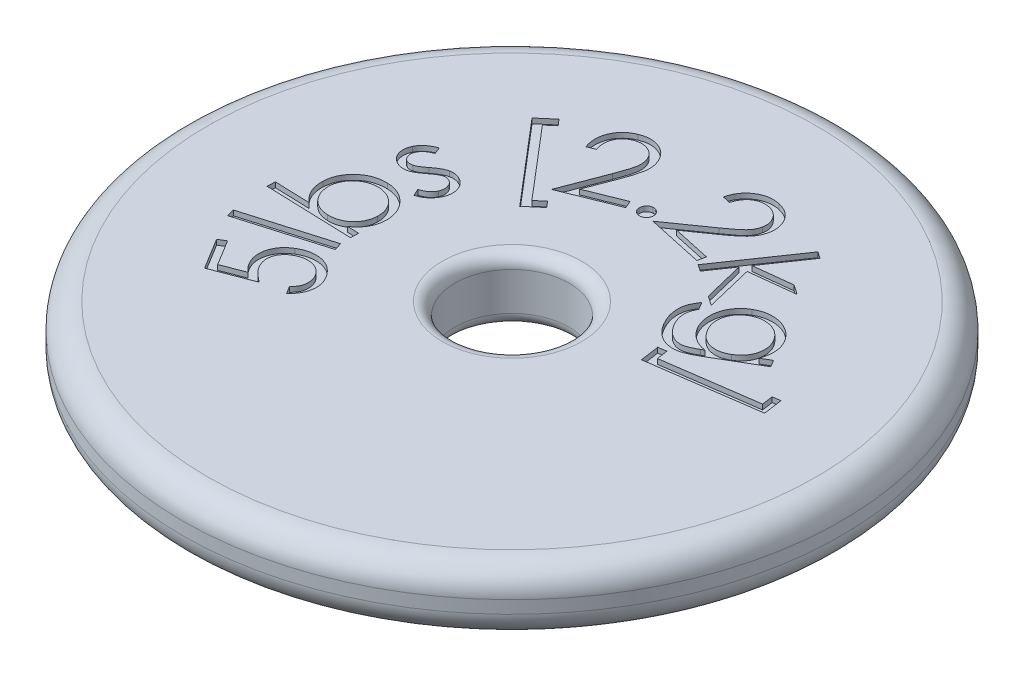
from build123d import *

# Parameters (mm, degrees)
SKETCH1_R           = 82.55
SKETCH1_R_2         = 14.2875
BOSS_EXTRUDE1_DEPTH = 7.9375
FILLET1_R           = 6.35
FILLET2_R           = 3.175
CUT_EXTRUDE1_DEPTH  = 1.27


with BuildPart() as part:
    # Sketch1 → Boss-Extrude1 (new body, symmetric)
    with BuildSketch(Plane(origin=(0, 0, 0), x_dir=(1, 0, 0), z_dir=(0, 1, 0))):
        Circle(SKETCH1_R)
        Circle(SKETCH1_R_2, mode=Mode.SUBTRACT)
    extrude(amount=BOSS_EXTRUDE1_DEPTH, both=True)

    # Fillet1
    fillet1_edges = [part.edges().sort_by_distance(p)[0] for p in [
        (-82.55, -7.9375, 0),
        (-82.55, 7.9375, 0),
    ]]
    fillet(fillet1_edges, radius=FILLET1_R)

    # Fillet2
    fillet2_edges = [part.edges().sort_by_distance(p)[0] for p in [
        (-14.2875, -7.9375, 0),
        (-14.2875, 7.9375, 0),
    ]]
    fillet(fillet2_edges, radius=FILLET2_R)

    # Sketch2 → Cut-Extrude1 (cut)
    with BuildSketch(Plane(origin=(0, 7.9375, 0), x_dir=(1, 0, 0), z_dir=(0, 1, 0))):
        Polygon((28.879652336, 3.539902753), (28.201233532, 8.30155473), (30.215289355, 8.585642603), (30.609620285, 5.82108598), (53.675859601, 9.107177059), (53.281528671, 11.871733683), (55.223502496, 12.147341321), (55.9019213, 7.385689345), align=None)
        with BuildLine():
            Line((45.56731607, 19.958879369), (46.584944275, 18.224671303))
            Line((46.584944275, 18.224671303), (35.899848121, 11.953537488))
            add(Edge.make_bspline(
                [(35.899848121, 11.953537488), (35.671200726, 11.822955682), (35.230003179, 11.570985297), (34.586055553, 11.215088871), (33.975223552, 10.910614423), (33.403679251, 10.64836999), (32.872861952, 10.422297335), (32.376523988, 10.252786494), (31.922142406, 10.108394493), (31.626452631, 10.051385369), (31.485885781, 10.024284016)],
                knots=[0, 0, 0, 0, 0.000789937, 0.001524262, 0.002206907, 0.002836804, 0.003410851, 0.003936523, 0.00441007, 0.004839182, 0.004839182, 0.004839182, 0.004839182], degree=3))
            add(Edge.make_bspline(
                [(31.485885781, 10.024284016), (31.299662275, 9.996159396), (30.932770023, 9.94074907), (30.380946149, 9.904805731), (29.8393038, 9.924686489), (29.303631844, 9.980933386), (28.778538099, 10.095007428), (28.257476375, 10.244968967), (27.749217659, 10.452639422), (27.246880057, 10.696893046), (26.762173723, 10.99035698), (26.292463873, 11.320969465), (25.84756059, 11.698836362), (25.414312004, 12.108097474), (25.002724881, 12.559344404), (24.611370368, 13.050023572), (24.237887164, 13.579862692), (24.0084847, 13.954949483), (23.891835301, 14.145678247)],
                knots=[0, 0, 0, 0, 0.000564875, 0.001112901, 0.001655901, 0.00218923, 0.002726438, 0.003265783, 0.003813793, 0.0043713, 0.00493995, 0.005511722, 0.006092618, 0.006689451, 0.007298687, 0.007923137, 0.00857132, 0.009241903, 0.009241903, 0.009241903, 0.009241903], degree=3))
            add(Edge.make_bspline(
                [(23.891835301, 14.145678247), (23.733427788, 14.430337114), (23.424521713, 14.985442435), (23.043888814, 15.838134554), (22.75534599, 16.683099408), (22.5491563, 17.51451422), (22.432332093, 18.322844179), (22.385169119, 19.097966988), (22.423543849, 19.834414752), (22.537560611, 20.546044595), (22.754359642, 21.254567288), (23.075169937, 21.986552812), (23.495281412, 22.758292423), (23.83659934, 23.267464012), (24.014798709, 23.533298439)],
                knots=[0, 0, 0, 0, 0.000976977, 0.001905175, 0.002796861, 0.003652483, 0.004471001, 0.005243866, 0.005978399, 0.006678955, 0.007400648, 0.008194581, 0.009073063, 0.010032764, 0.010032764, 0.010032764, 0.010032764], degree=3))
            Line((24.014798709, 23.533298439), (25.117229264, 21.659166495))
            add(Edge.make_bspline(
                [(25.117229264, 21.659166495), (24.983319157, 21.403609578), (24.72232343, 20.905519743), (24.449957881, 20.118513977), (24.305568591, 19.324953184), (24.277810737, 18.52292662), (24.380774789, 17.707386517), (24.607026167, 16.874082664), (24.949090862, 16.012690051), (25.25766562, 15.454067411), (25.418277608, 15.163306452)],
                knots=[0, 0, 0, 0, 0.000864703, 0.001685339, 0.002487068, 0.003276141, 0.004083435, 0.004943249, 0.005860536, 0.006856242, 0.006856242, 0.006856242, 0.006856242], degree=3))
            add(Edge.make_bspline(
                [(25.418277608, 15.163306452), (25.503960746, 15.01929734), (25.671677385, 14.737413123), (25.951740571, 14.343407735), (26.233442888, 13.972217777), (26.531041692, 13.633703963), (26.836378123, 13.323147945), (27.151016631, 13.041174498), (27.478186491, 12.789795285), (27.922669049, 12.502955216), (28.482511876, 12.208855008), (29.160864236, 11.9579273), (29.832231358, 11.817035276), (30.393619511, 11.794948432), (30.849172436, 11.849342287), (31.220157804, 11.920588944), (31.618546172, 12.038761971), (32.046208114, 12.191167293), (32.501059407, 12.384301515), (32.98435068, 12.614337057), (33.49700409, 12.880487356), (33.842746158, 13.080022645), (34.021476059, 13.18317157)],
                knots=[0, 0, 0, 0, 0.000502503, 0.000983602, 0.001449205, 0.001899936, 0.002334687, 0.002755122, 0.003166436, 0.003571006, 0.004340993, 0.005058626, 0.005733857, 0.006391417, 0.006732766, 0.007108633, 0.00752332, 0.007977963, 0.008470145, 0.009005005, 0.009583436, 0.010202449, 0.010202449, 0.010202449, 0.010202449], degree=3))
            Line((34.021476059, 13.18317157), (34.712615215, 13.585982734))
            add(Edge.make_bspline(
                [(34.712615215, 13.585982734), (34.416939375, 13.636671292), (33.829721649, 13.737339713), (32.982840037, 14.015923063), (32.173491788, 14.381448472), (31.413683963, 14.845397756), (30.704277698, 15.385485944), (30.0668552, 16.006457432), (29.489692286, 16.690878864), (29.170697398, 17.197306686), (29.009657149, 17.452969914)],
                knots=[0, 0, 0, 0, 0.000898915, 0.001785262, 0.002665707, 0.003557957, 0.004450126, 0.005334727, 0.006222897, 0.007128418, 0.007128418, 0.007128418, 0.007128418], degree=3))
            add(Edge.make_bspline(
                [(29.009657149, 17.452969914), (28.922932741, 17.607426759), (28.749821538, 17.91573916), (28.526333513, 18.392728023), (28.33768262, 18.881948641), (28.183648389, 19.379814774), (28.051726052, 19.88661849), (27.966583935, 20.404957313), (27.905071628, 20.931239586), (27.880688592, 21.463859394), (27.888229911, 21.996426455), (27.932380619, 22.521448715), (28.000882631, 23.036716393), (28.115159723, 23.538273957), (28.252742518, 24.030823072), (28.427630359, 24.511042285), (28.635806899, 24.978634267), (28.877425383, 25.431609238), (29.149886628, 25.867959618), (29.444955837, 26.287306894), (29.767349166, 26.684725719), (30.12351507, 27.051078288), (30.494010487, 27.407595191), (30.89966893, 27.730390587), (31.324095214, 28.040802631), (31.625782644, 28.223629871), (31.77845389, 28.316151003)],
                knots=[0, 0, 0, 0, 0.000531285, 0.001060502, 0.00157863, 0.002102984, 0.002623345, 0.003148246, 0.003677361, 0.004212222, 0.004746544, 0.005274025, 0.005792118, 0.006304454, 0.006815823, 0.00732552, 0.007836115, 0.008350167, 0.008864342, 0.009378446, 0.009887702, 0.010397539, 0.010910453, 0.011428963, 0.011951444, 0.012486741, 0.012486741, 0.012486741, 0.012486741], degree=3))
            add(Edge.make_bspline(
                [(31.77845389, 28.316151003), (31.934020926, 28.404917325), (32.242371154, 28.580861513), (32.7255631, 28.798503611), (33.212667848, 28.991635971), (33.710126724, 29.148341801), (34.217082994, 29.272341256), (34.732910941, 29.360451278), (35.25832248, 29.416257409), (35.78948233, 29.436835386), (36.321972842, 29.424391053), (36.848961582, 29.378069527), (37.368529724, 29.296276579), (37.881148236, 29.184577251), (38.382138245, 29.028021435), (38.877922082, 28.846791987), (39.363613277, 28.626351926), (39.838175741, 28.370652763), (40.296675545, 28.090575532), (40.730595112, 27.781748153), (41.143882893, 27.45809397), (41.525090681, 27.103606006), (41.882026051, 26.729935153), (42.215117776, 26.335631661), (42.515935074, 25.913437363), (42.69833683, 25.619040045), (42.790039093, 25.471032147)],
                knots=[0, 0, 0, 0, 0.000537041, 0.001064471, 0.001588087, 0.002108396, 0.002627737, 0.003152639, 0.003677078, 0.004211753, 0.00474616, 0.005273999, 0.005797529, 0.006323201, 0.006846302, 0.007370861, 0.007906007, 0.008444752, 0.008987255, 0.009516642, 0.010041766, 0.010560882, 0.011076715, 0.011591378, 0.012107942, 0.012630217, 0.012630217, 0.012630217, 0.012630217], degree=3))
            add(Edge.make_bspline(
                [(42.790039093, 25.471032147), (42.929227178, 25.219655952), (43.20359819, 24.72413695), (43.502609163, 23.932736591), (43.718479445, 23.126374292), (43.833201831, 22.291989523), (43.850602641, 21.426574943), (43.75629599, 20.51804658), (43.556869677, 19.563192371), (43.347619717, 18.923906931), (43.239491551, 18.593561527)],
                knots=[0, 0, 0, 0, 0.000861026, 0.001697275, 0.002530326, 0.003360838, 0.004217509, 0.005120813, 0.006095432, 0.007137578, 0.007137578, 0.007137578, 0.007137578], degree=3))
            Line((43.239491551, 18.593561527), (45.56731607, 19.958879369))
        make_face()
        with BuildLine():
            add(Edge.make_bspline(
                [(41.259356668, 24.275319006), (41.110048635, 24.511571638), (40.815001553, 24.978429639), (40.266354959, 25.59784455), (39.648641984, 26.140087471), (38.962295849, 26.597110363), (38.226202494, 26.959336996), (37.457468643, 27.230404975), (36.654860729, 27.374862127), (35.83600033, 27.422183601), (35.015882391, 27.364225685), (34.214976463, 27.196368344), (33.43923938, 26.925745342), (32.955553423, 26.666318686), (32.711279745, 26.535301644)],
                knots=[0, 0, 0, 0, 0.000837313, 0.001654612, 0.00247191, 0.00329746, 0.004120436, 0.004927664, 0.005734334, 0.006558238, 0.00738296, 0.008192922, 0.009006948, 0.009837502, 0.009837502, 0.009837502, 0.009837502], degree=3))
            add(Edge.make_bspline(
                [(32.711279745, 26.535301644), (32.533721205, 26.425610883), (32.184777934, 26.210043369), (31.70843204, 25.833569288), (31.282565057, 25.425840206), (30.907825268, 24.986830605), (30.579813446, 24.518077356), (30.315748927, 24.009413483), (30.092775734, 23.473962242), (29.925028683, 22.911157379), (29.808877926, 22.333640827), (29.759250737, 21.747855135), (29.766040311, 21.16086659), (29.840430461, 20.572899286), (29.972874258, 19.985224144), (30.164760297, 19.397100557), (30.421082253, 18.808987326), (30.631849133, 18.427980141), (30.739625098, 18.233151538)],
                knots=[0, 0, 0, 0, 0.000625701, 0.001229646, 0.001817419, 0.002391841, 0.00295875, 0.003529672, 0.004107636, 0.004696524, 0.005288594, 0.005871714, 0.006456912, 0.007046471, 0.007646189, 0.008261649, 0.008899699, 0.009567393, 0.009567393, 0.009567393, 0.009567393], degree=3))
            add(Edge.make_bspline(
                [(30.739625098, 18.233151538), (30.857851389, 18.041520729), (31.088352938, 17.667905033), (31.483431388, 17.155540958), (31.902580227, 16.696631827), (32.347811745, 16.290558577), (32.824180289, 15.945072653), (33.324584227, 15.648439543), (33.859205025, 15.417929199), (34.411352176, 15.232879381), (34.980976007, 15.11603365), (35.554808727, 15.05601247), (36.131961781, 15.055165436), (36.710682378, 15.119393371), (37.289641629, 15.24897242), (37.870315748, 15.4372977), (38.452301031, 15.687424735), (38.828648125, 15.896319323), (39.020574617, 16.002849721)],
                knots=[0, 0, 0, 0, 0.000675125, 0.001316266, 0.001937483, 0.002537876, 0.003120518, 0.003700113, 0.004279164, 0.004863778, 0.005444225, 0.006019711, 0.006592127, 0.007172279, 0.007762798, 0.008368883, 0.009001358, 0.009659573, 0.009659573, 0.009659573, 0.009659573], degree=3))
            add(Edge.make_bspline(
                [(39.020574617, 16.002849721), (39.261942646, 16.155562903), (39.735665137, 16.455286396), (40.366968829, 16.99206202), (40.902470509, 17.593833047), (41.350039509, 18.246623151), (41.697977524, 18.94799263), (41.947290978, 19.685168748), (42.09263813, 20.454316078), (42.128064065, 21.245907325), (42.065148612, 22.039473511), (41.902860655, 22.817563898), (41.642364124, 23.571951533), (41.387707687, 24.039610978), (41.259356668, 24.275319006)],
                knots=[0, 0, 0, 0, 0.000856126, 0.001680281, 0.00247608, 0.003266393, 0.004047645, 0.004817294, 0.005594011, 0.006387831, 0.007187506, 0.007975849, 0.00876706, 0.009571085, 0.009571085, 0.009571085, 0.009571085], degree=3))
        make_face(mode=Mode.SUBTRACT)
        Polygon((27.57659226, 49.061848625), (29.238718328, 47.917016895), (22.284925593, 37.800096489), (31.765828371, 38.889806692), (34.195415711, 37.219200388), (22.954864162, 35.938684897), (25.795742901, 24.104516895), (23.459438147, 25.711521435), (20.983209514, 35.900523839), (17.018699632, 30.13396401), (15.356573564, 31.278795741), align=None)
        with BuildLine():
            Line((5.786038782, 48.696133268), (3.8059039, 49.124385138))
            add(Edge.make_bspline(
                [(3.8059039, 49.124385138), (3.87220874, 49.371687681), (4.002383575, 49.857211332), (4.268934345, 50.550191258), (4.579769011, 51.199148228), (4.954377202, 51.794187481), (5.367654793, 52.349297231), (5.840102258, 52.853330809), (6.360954961, 53.311033977), (6.929725035, 53.71766144), (7.530560963, 54.066341349), (8.153184558, 54.353861909), (8.791417815, 54.570470438), (9.444865337, 54.720922841), (10.11435772, 54.799584982), (10.798708067, 54.818237069), (11.499341596, 54.762891214), (11.964574552, 54.673533022), (12.201336592, 54.62805768)],
                knots=[0, 0, 0, 0, 0.000767637, 0.001507085, 0.002223903, 0.002922802, 0.003613096, 0.00429711, 0.004991156, 0.005690094, 0.006391164, 0.007072294, 0.007744068, 0.008409564, 0.009080119, 0.009762989, 0.010460549, 0.011183424, 0.011183424, 0.011183424, 0.011183424], degree=3))
            add(Edge.make_bspline(
                [(12.201336592, 54.62805768), (12.432913755, 54.572953678), (12.886414315, 54.465042796), (13.532609266, 54.234478368), (14.13180696, 53.95299056), (14.683992008, 53.621412473), (15.194432177, 53.242828924), (15.65249295, 52.808733022), (16.062676249, 52.323966475), (16.424781869, 51.798185656), (16.729728369, 51.240235534), (16.989035965, 50.672509139), (17.177961668, 50.091231471), (17.31761605, 49.504746904), (17.388919372, 48.905855118), (17.399095987, 48.299919264), (17.361575105, 47.684084709), (17.282755316, 47.277889481), (17.242836325, 47.072168257)],
                knots=[0, 0, 0, 0, 0.000713714, 0.001397675, 0.002053949, 0.002696771, 0.003326853, 0.003956735, 0.004585432, 0.005228771, 0.005868355, 0.006490887, 0.00709829, 0.007698952, 0.008296929, 0.008903399, 0.009515446, 0.010143514, 0.010143514, 0.010143514, 0.010143514], degree=3))
            add(Edge.make_bspline(
                [(17.242836325, 47.072168257), (17.169732929, 46.78566401), (17.024817906, 46.217718173), (16.676350694, 45.410388067), (16.239272673, 44.648840443), (15.7826189, 44.057082187), (15.355098337, 43.592248104), (14.974950753, 43.21828243), (14.538625493, 42.821701024), (14.045842711, 42.400803736), (13.492850331, 41.962027012), (12.885889874, 41.494409129), (12.221616537, 41.003657079), (11.755343711, 40.674361321), (11.514437554, 40.504226217)],
                knots=[0, 0, 0, 0, 0.00088587, 0.001756086, 0.002628078, 0.003514303, 0.003991481, 0.004522174, 0.005113438, 0.005760066, 0.006465966, 0.007230941, 0.008058633, 0.008943396, 0.008943396, 0.008943396, 0.008943396], degree=3))
            Line((11.514437554, 40.504226217), (5.175461859, 36.064823172))
            Line((5.175461859, 36.064823172), (14.711486165, 34.004126056))
            Line((14.711486165, 34.004126056), (14.278994178, 32.011270821))
            Line((14.278994178, 32.011270821), (0.248445299, 35.042954849))
            Line((0.248445299, 35.042954849), (9.987995246, 41.865303941))
            add(Edge.make_bspline(
                [(9.987995246, 41.865303941), (10.224423761, 42.030106993), (10.67934515, 42.347211016), (11.327614042, 42.812466405), (11.913415683, 43.248560951), (12.435862842, 43.656483723), (12.898993135, 44.033008707), (13.300348855, 44.379579369), (13.64431134, 44.691944952), (14.008619789, 45.074790315), (14.393980492, 45.546774963), (14.761559676, 46.152010244), (15.048091893, 46.791389406), (15.165642854, 47.241151276), (15.224540385, 47.466499187)],
                knots=[0, 0, 0, 0, 0.000864589, 0.00166359, 0.00239374, 0.00305532, 0.003651988, 0.004184102, 0.004646177, 0.005045041, 0.005768823, 0.00646911, 0.007163972, 0.007861726, 0.007861726, 0.007861726, 0.007861726], degree=3))
            add(Edge.make_bspline(
                [(15.224540385, 47.466499187), (15.252006503, 47.610223212), (15.306081577, 47.893185924), (15.327022545, 48.321415823), (15.317833592, 48.743295584), (15.257733807, 49.160236677), (15.150324269, 49.569040723), (14.999964901, 49.970420009), (14.809146083, 50.365556805), (14.575133402, 50.748247594), (14.313690459, 51.115708282), (14.013430697, 51.446508392), (13.691451676, 51.74715539), (13.33633633, 52.005135802), (12.957594823, 52.231425599), (12.552519529, 52.421645871), (12.122334483, 52.582598889), (11.820671228, 52.653980563), (11.667081784, 52.690323973)],
                knots=[0, 0, 0, 0, 0.000438458, 0.000863232, 0.001283196, 0.001702947, 0.002123574, 0.002548877, 0.002986945, 0.003437795, 0.003893248, 0.004337631, 0.00477574, 0.005212493, 0.005651709, 0.006097426, 0.006553509, 0.007026582, 0.007026582, 0.007026582, 0.007026582], degree=3))
            add(Edge.make_bspline(
                [(11.667081784, 52.690323973), (11.505021779, 52.72175045), (11.185578287, 52.783696538), (10.705155055, 52.820833649), (10.23693339, 52.811456873), (9.779882624, 52.763856542), (9.337589956, 52.658627836), (8.905231083, 52.514386903), (8.484596447, 52.322597498), (8.078395934, 52.085302301), (7.693198541, 51.805911397), (7.332133581, 51.484887946), (7.004932504, 51.119516107), (6.698278901, 50.71804856), (6.430517839, 50.270094309), (6.182307269, 49.785513163), (5.966182299, 49.257123869), (5.847134874, 48.886394532), (5.786038782, 48.696133268)],
                knots=[0, 0, 0, 0, 0.000494933, 0.000975583, 0.001442073, 0.00189861, 0.002351172, 0.002803038, 0.00326414, 0.003735385, 0.004212035, 0.004689514, 0.005181806, 0.005681295, 0.006202692, 0.006745029, 0.007313537, 0.007912895, 0.007912895, 0.007912895, 0.007912895], degree=3))
        make_face()
        with BuildLine():
            add(Edge.make_bspline(
                [(-2.738163767, 38.064674253), (-2.620649897, 38.067682738), (-2.389022811, 38.073612648), (-2.047519474, 38.005672535), (-1.732453424, 37.85956108), (-1.445882045, 37.656129363), (-1.197941311, 37.406383725), (-1.004897053, 37.115111604), (-0.878297849, 36.786225882), (-0.849221942, 36.552016141), (-0.834351, 36.432229008)],
                knots=[0, 0, 0, 0, 0.000351955, 0.000693726, 0.001033412, 0.001386336, 0.001743136, 0.002083008, 0.00242792, 0.002789003, 0.002789003, 0.002789003, 0.002789003], degree=3))
            add(Edge.make_bspline(
                [(-0.834351, 36.432229008), (-0.828683236, 36.313100523), (-0.817629, 36.080755912), (-0.897643754, 35.740972178), (-1.033377332, 35.421167854), (-1.23802148, 35.133768874), (-1.48404598, 34.881764511), (-1.775639175, 34.692825181), (-2.09750204, 34.558840894), (-2.328433454, 34.53021774), (-2.445595658, 34.515695888)],
                knots=[0, 0, 0, 0, 0.00035617, 0.000694663, 0.001036512, 0.001392909, 0.001746699, 0.00208657, 0.002429076, 0.002781797, 0.002781797, 0.002781797, 0.002781797], degree=3))
            add(Edge.make_bspline(
                [(-2.445595658, 34.515695888), (-2.563257429, 34.512104405), (-2.795465842, 34.505016525), (-3.134546265, 34.581412153), (-3.454271276, 34.720141629), (-3.740091795, 34.926679448), (-3.987303804, 35.179920222), (-4.176997862, 35.471985952), (-4.304196706, 35.797199394), (-4.336967882, 36.026954659), (-4.353648543, 36.143901016)],
                knots=[0, 0, 0, 0, 0.000351955, 0.000694592, 0.001032554, 0.001391389, 0.00174523, 0.002088653, 0.002429607, 0.002783066, 0.002783066, 0.002783066, 0.002783066], degree=3))
            add(Edge.make_bspline(
                [(-4.353648543, 36.143901016), (-4.356862744, 36.264301321), (-4.363161772, 36.500255702), (-4.293387308, 36.845894244), (-4.1550315, 37.16681453), (-3.948827647, 37.452887634), (-3.699768515, 37.701245935), (-3.409251583, 37.893011318), (-3.085200026, 38.020291523), (-2.855143329, 38.049713648), (-2.738163767, 38.064674253)],
                knots=[0, 0, 0, 0, 0.000360435, 0.000706362, 0.001048211, 0.001401136, 0.001757936, 0.002097807, 0.002438761, 0.002791482, 0.002791482, 0.002791482, 0.002791482], degree=3))
        make_face()
        with BuildLine():
            Line((-22.416178273, 43.55267689), (-24.2860701, 42.797935971))
            add(Edge.make_bspline(
                [(-24.2860701, 42.797935971), (-24.369582099, 43.038313387), (-24.533697512, 43.510696277), (-24.701448395, 44.230873761), (-24.807099917, 44.940050288), (-24.834071287, 45.638885327), (-24.803792276, 46.328113892), (-24.694041554, 47.006181578), (-24.526821079, 47.676726481), (-24.282441611, 48.326653525), (-23.985068597, 48.950798426), (-23.632549632, 49.533015252), (-23.230247421, 50.069547792), (-22.776594917, 50.55674721), (-22.270266674, 50.998042896), (-21.714900318, 51.391222922), (-21.108862212, 51.739018473), (-20.676910736, 51.925405428), (-20.457243978, 52.02019158)],
                knots=[0, 0, 0, 0, 0.00076295, 0.001499328, 0.002214703, 0.002910715, 0.003594216, 0.004280867, 0.004967831, 0.005664102, 0.006360114, 0.007039301, 0.007702456, 0.008368492, 0.009032622, 0.009713818, 0.010406983, 0.011124253, 0.011124253, 0.011124253, 0.011124253], degree=3))
            add(Edge.make_bspline(
                [(-20.457243978, 52.02019158), (-20.235175882, 52.103008066), (-19.800709864, 52.265034712), (-19.141387155, 52.441208957), (-18.49035925, 52.542648639), (-17.851259111, 52.58309077), (-17.219982296, 52.552855106), (-16.599985847, 52.455392059), (-15.989966408, 52.288963766), (-15.399014622, 52.054844322), (-14.836006428, 51.76768596), (-14.308135288, 51.442159179), (-13.82473863, 51.074963278), (-13.385894982, 50.665829801), (-12.990495446, 50.215808046), (-12.641330278, 49.723442156), (-12.332848413, 49.193729645), (-12.169673142, 48.815104216), (-12.087251991, 48.623857445)],
                knots=[0, 0, 0, 0, 0.000710773, 0.001390595, 0.002043077, 0.002684471, 0.003308475, 0.003935167, 0.004563649, 0.005201431, 0.005838578, 0.006457475, 0.007059587, 0.007656601, 0.008254518, 0.008853396, 0.009465047, 0.010089324, 0.010089324, 0.010089324, 0.010089324], degree=3))
            add(Edge.make_bspline(
                [(-12.087251991, 48.623857445), (-11.986379816, 48.347660521), (-11.786004836, 47.799016126), (-11.620708038, 46.938928677), (-11.559022972, 46.067426147), (-11.605336594, 45.32615771), (-11.695914099, 44.705274051), (-11.798906566, 44.184422658), (-11.941141875, 43.6157001), (-12.111152496, 42.993329362), (-12.315562476, 42.320614188), (-12.551435511, 41.595720009), (-12.831143876, 40.823472025), (-13.028202959, 40.29188992), (-13.130320902, 40.016418877)],
                knots=[0, 0, 0, 0, 0.000880935, 0.001749911, 0.002616929, 0.003496107, 0.003971624, 0.004498833, 0.005088103, 0.005729973, 0.006434203, 0.007197153, 0.008016594, 0.008897977, 0.008897977, 0.008897977, 0.008897977], degree=3))
            Line((-13.130320902, 40.016418877), (-15.860956585, 32.825179561))
            Line((-15.860956585, 32.825179561), (-6.863427205, 36.458960276))
            Line((-6.863427205, 36.458960276), (-6.104446169, 34.576348097))
            Line((-6.104446169, 34.576348097), (-19.34209307, 29.229559902))
            Line((-19.34209307, 29.229559902), (-15.144376724, 40.279306163))
            add(Edge.make_bspline(
                [(-15.144376724, 40.279306163), (-15.041854044, 40.547561967), (-14.844836253, 41.063069028), (-14.573444487, 41.809418963), (-14.335252892, 42.496177121), (-14.13122503, 43.123695262), (-13.959754943, 43.692972377), (-13.824497744, 44.203599784), (-13.720351204, 44.654357286), (-13.628872559, 45.171845475), (-13.578183388, 45.7749902), (-13.605427908, 46.477999082), (-13.73146545, 47.162614217), (-13.887509503, 47.596696484), (-13.965624053, 47.813994999)],
                knots=[0, 0, 0, 0, 0.000861527, 0.001655596, 0.002382377, 0.003042094, 0.003635043, 0.004165736, 0.004626565, 0.005022511, 0.005741545, 0.006437558, 0.007127799, 0.007819679, 0.007819679, 0.007819679, 0.007819679], degree=3))
            add(Edge.make_bspline(
                [(-13.965624053, 47.813994999), (-14.023774014, 47.946730051), (-14.139158308, 48.21011011), (-14.356117949, 48.577847219), (-14.605218939, 48.916821334), (-14.883975517, 49.227955419), (-15.200863015, 49.503686621), (-15.54785493, 49.75107092), (-15.924997481, 49.973553663), (-16.334850011, 50.155586801), (-16.757451375, 50.308970355), (-17.189335607, 50.416987136), (-17.623176743, 50.473507609), (-18.058765024, 50.497953144), (-18.498140573, 50.471459867), (-18.939155486, 50.397587277), (-19.382624852, 50.284341392), (-19.670903056, 50.1756816), (-19.816986233, 50.12061893)],
                knots=[0, 0, 0, 0, 0.000434441, 0.000862042, 0.001277595, 0.001694875, 0.0021125, 0.002534919, 0.00297198, 0.003423607, 0.00387825, 0.004319426, 0.004755973, 0.005188984, 0.005626457, 0.006073281, 0.006528872, 0.00699692, 0.00699692, 0.00699692, 0.00699692], degree=3))
            add(Edge.make_bspline(
                [(-19.816986233, 50.12061893), (-19.968214081, 50.055668588), (-20.264361779, 49.928477105), (-20.679237983, 49.690660515), (-21.061143753, 49.427186069), (-21.402411143, 49.124386618), (-21.715623232, 48.799370908), (-21.986372248, 48.435385691), (-22.224732934, 48.043561347), (-22.42903866, 47.62432852), (-22.589695715, 47.179504946), (-22.704995052, 46.713485854), (-22.772579047, 46.22888563), (-22.791262773, 45.726489317), (-22.772723528, 45.206821443), (-22.695065167, 44.670478221), (-22.583817587, 44.113976082), (-22.472933879, 43.742709139), (-22.416178273, 43.55267689)],
                knots=[0, 0, 0, 0, 0.000493386, 0.000966193, 0.001432008, 0.001882739, 0.002332631, 0.00278378, 0.003240455, 0.003706964, 0.004180435, 0.004656576, 0.005144687, 0.00564547, 0.006163199, 0.006702294, 0.007269425, 0.007864085, 0.007864085, 0.007864085, 0.007864085], degree=3))
        make_face()
        Polygon((-37.278407741, 42.299559778), (-33.627666555, 45.407565921), (-32.313230123, 43.864163144), (-34.441769119, 42.053632962), (-19.402072271, 24.376583016), (-17.273533275, 26.187113197), (-16.005738136, 24.698831947), (-19.656479322, 21.590825804), align=None)
        with BuildLine():
            Line((-42.391988048, 24.19230782), (-41.717809362, 22.470820106))
            add(Edge.make_bspline(
                [(-41.717809362, 22.470820106), (-41.884115927, 22.402283672), (-42.207080354, 22.269187122), (-42.661151541, 22.040600992), (-43.070497985, 21.793532824), (-43.438311167, 21.532241033), (-43.757544957, 21.247105915), (-44.031070476, 20.944855594), (-44.261326617, 20.624171243), (-44.377807286, 20.393416822), (-44.435724693, 20.278679347)],
                knots=[0, 0, 0, 0, 0.000539496, 0.001047691, 0.001523265, 0.001972798, 0.002399219, 0.002804522, 0.003193921, 0.003579026, 0.003579026, 0.003579026, 0.003579026], degree=3))
            add(Edge.make_bspline(
                [(-44.435724693, 20.278679347), (-44.49363745, 20.131977727), (-44.606882233, 19.845111857), (-44.67923651, 19.390826993), (-44.662232617, 18.9354274), (-44.553841292, 18.493134938), (-44.382219258, 18.078723927), (-44.13558512, 17.726146652), (-43.833773473, 17.432033232), (-43.58875884, 17.303550327), (-43.464737781, 17.238515085)],
                knots=[0, 0, 0, 0, 0.000472045, 0.000923055, 0.00136859, 0.001830374, 0.002282459, 0.002705898, 0.003113831, 0.003531972, 0.003531972, 0.003531972, 0.003531972], degree=3))
            add(Edge.make_bspline(
                [(-43.464737781, 17.238515085), (-43.3474293, 17.192209468), (-43.112879204, 17.099624629), (-42.728229527, 17.055569068), (-42.325084002, 17.06385364), (-42.056284883, 17.12864342), (-41.917094886, 17.162192969)],
                knots=[0, 0, 0, 0, 0.000376798, 0.000753382, 0.001152156, 0.001580408, 0.001580408, 0.001580408, 0.001580408], degree=3))
            add(Edge.make_bspline(
                [(-41.917094886, 17.162192969), (-41.840254973, 17.184759405), (-41.675191172, 17.233235536), (-41.423230311, 17.342863601), (-41.144166999, 17.478411829), (-40.846516878, 17.654073198), (-40.524221149, 17.85779073), (-40.177824566, 18.092132401), (-39.811598584, 18.364637119), (-39.559326819, 18.558267146), (-39.428145901, 18.658954454)],
                knots=[0, 0, 0, 0, 0.000240045, 0.000515652, 0.000822849, 0.001170487, 0.001551626, 0.001966768, 0.00242472, 0.002920832, 0.002920832, 0.002920832, 0.002920832], degree=3))
            add(Edge.make_bspline(
                [(-39.428145901, 18.658954454), (-39.267994012, 18.781830949), (-38.957254954, 19.020245411), (-38.49124944, 19.343881188), (-38.049460154, 19.635982248), (-37.627730234, 19.884932083), (-37.226528934, 20.096318403), (-36.846170693, 20.26386074), (-36.488610021, 20.402374852), (-36.251615237, 20.459172109), (-36.137814704, 20.486445106)],
                knots=[0, 0, 0, 0, 0.000605491, 0.001174821, 0.001701688, 0.002193999, 0.002643471, 0.003061074, 0.003440725, 0.003791426, 0.003791426, 0.003791426, 0.003791426], degree=3))
            add(Edge.make_bspline(
                [(-36.137814704, 20.486445106), (-35.920689435, 20.518603906), (-35.491992238, 20.58209899), (-34.840820044, 20.559532095), (-34.200785661, 20.426784777), (-33.795197101, 20.263809214), (-33.589504074, 20.181156645)],
                knots=[0, 0, 0, 0, 0.000657423, 0.001298032, 0.001943338, 0.00260736, 0.00260736, 0.00260736, 0.00260736], degree=3))
            add(Edge.make_bspline(
                [(-33.589504074, 20.181156645), (-33.449536715, 20.113192825), (-33.172281522, 19.978566279), (-32.787287609, 19.732173201), (-32.436915038, 19.453151556), (-32.117330943, 19.149167769), (-31.834454194, 18.810438284), (-31.58982425, 18.438665198), (-31.371039239, 18.040563053), (-31.196036425, 17.612830163), (-31.056313483, 17.172225284), (-30.960374683, 16.725086429), (-30.920285653, 16.275528669), (-30.918723386, 15.823990428), (-30.966099537, 15.369286332), (-31.060543759, 14.913675374), (-31.200651203, 14.456196297), (-31.328102442, 14.159108424), (-31.393123198, 14.007545533)],
                knots=[0, 0, 0, 0, 0.00046649, 0.00092405, 0.001367725, 0.001808554, 0.002245039, 0.00268839, 0.003141845, 0.003605649, 0.004072331, 0.004527211, 0.004974438, 0.005423891, 0.005879974, 0.006343157, 0.006817937, 0.007312415, 0.007312415, 0.007312415, 0.007312415], degree=3))
            add(Edge.make_bspline(
                [(-31.393123198, 14.007545533), (-31.491806159, 13.809934263), (-31.688318126, 13.416421757), (-32.063168739, 12.872080819), (-32.493427389, 12.367102036), (-32.982764415, 11.913549559), (-33.513896359, 11.516005504), (-34.078836799, 11.184898457), (-34.674779041, 10.92777266), (-35.0903631, 10.812862589), (-35.298271435, 10.755375395)],
                knots=[0, 0, 0, 0, 0.000661961, 0.001318194, 0.001976778, 0.002648807, 0.003315355, 0.003963317, 0.004609152, 0.005255711, 0.005255711, 0.005255711, 0.005255711], degree=3))
            Line((-35.298271435, 10.755375395), (-36.074212941, 12.493823578))
            add(Edge.make_bspline(
                [(-36.074212941, 12.493823578), (-35.89648039, 12.551710467), (-35.553146591, 12.66353312), (-35.069512172, 12.873872601), (-34.632567616, 13.108942561), (-34.242175279, 13.374947953), (-33.895321152, 13.665485743), (-33.602962919, 13.993047236), (-33.346417149, 14.338790733), (-33.219883459, 14.593384239), (-33.157012087, 14.719885277)],
                knots=[0, 0, 0, 0, 0.000560498, 0.001082739, 0.001579846, 0.002046741, 0.00249791, 0.002933157, 0.003361493, 0.003784507, 0.003784507, 0.003784507, 0.003784507], degree=3))
            add(Edge.make_bspline(
                [(-33.157012087, 14.719885277), (-33.085320816, 14.898701477), (-32.944653912, 15.249560393), (-32.850595457, 15.804596731), (-32.868316374, 16.359203317), (-32.993254017, 16.89683931), (-33.200044775, 17.396366765), (-33.486355855, 17.833018869), (-33.859677085, 18.18319363), (-34.156342818, 18.341568596), (-34.306083935, 18.421507873)],
                knots=[0, 0, 0, 0, 0.000576718, 0.001131591, 0.001674591, 0.002231081, 0.002778385, 0.003288769, 0.003786798, 0.004294374, 0.004294374, 0.004294374, 0.004294374], degree=3))
            add(Edge.make_bspline(
                [(-34.306083935, 18.421507873), (-34.436148618, 18.472483616), (-34.692117711, 18.572804582), (-35.099989536, 18.647720322), (-35.515930883, 18.637666182), (-35.787975327, 18.578625058), (-35.925808828, 18.548711399)],
                knots=[0, 0, 0, 0, 0.00041842, 0.000823457, 0.001234836, 0.001657318, 0.001657318, 0.001657318, 0.001657318], degree=3))
            add(Edge.make_bspline(
                [(-35.925808828, 18.548711399), (-35.99972452, 18.524416089), (-36.16024636, 18.471654249), (-36.410312024, 18.360080797), (-36.684063245, 18.207600696), (-36.993373176, 18.031399916), (-37.323063387, 17.808523142), (-37.686925909, 17.55832605), (-38.074935217, 17.270108057), (-38.340317942, 17.062445229), (-38.478359576, 16.954427211)],
                knots=[0, 0, 0, 0, 0.000233322, 0.000506703, 0.000819726, 0.001173159, 0.001574181, 0.002012905, 0.002497987, 0.00302383, 0.00302383, 0.00302383, 0.00302383], degree=3))
            add(Edge.make_bspline(
                [(-38.478359576, 16.954427211), (-38.629974762, 16.837130329), (-38.922100121, 16.611127943), (-39.362663374, 16.305786369), (-39.778767421, 16.032831744), (-40.180837663, 15.803477984), (-40.561339573, 15.606113078), (-40.926764937, 15.448703878), (-41.273563379, 15.326870947), (-41.502432514, 15.274789221), (-41.611806424, 15.249899967)],
                knots=[0, 0, 0, 0, 0.00057497, 0.001107826, 0.001607675, 0.002067332, 0.002495898, 0.002892865, 0.003260266, 0.003596547, 0.003596547, 0.003596547, 0.003596547], degree=3))
            add(Edge.make_bspline(
                [(-41.611806424, 15.249899967), (-41.823345051, 15.216643853), (-42.243745378, 15.150552466), (-42.883912426, 15.190396726), (-43.520670372, 15.310838364), (-43.922172024, 15.478480755), (-44.126196114, 15.563668664)],
                knots=[0, 0, 0, 0, 0.000640581, 0.001273055, 0.001913355, 0.002574881, 0.002574881, 0.002574881, 0.002574881], degree=3))
            add(Edge.make_bspline(
                [(-44.126196114, 15.563668664), (-44.255793882, 15.628231152), (-44.510398752, 15.755069169), (-44.869006521, 15.973912796), (-45.190405361, 16.227609477), (-45.476892336, 16.508855602), (-45.740928057, 16.808866536), (-45.959545372, 17.144400633), (-46.152324666, 17.500788497), (-46.308095409, 17.88181709), (-46.426216057, 18.276655866), (-46.502326454, 18.678893769), (-46.542067554, 19.083446455), (-46.537079807, 19.492741554), (-46.49040422, 19.904771284), (-46.399552819, 20.319063384), (-46.268526759, 20.73481452), (-46.152483852, 21.006053127), (-46.093610644, 21.143663322)],
                knots=[0, 0, 0, 0, 0.000434276, 0.000853169, 0.001257783, 0.001659589, 0.002056488, 0.002453974, 0.002858033, 0.003270634, 0.003686512, 0.004092324, 0.004496939, 0.004904012, 0.00531794, 0.00573876, 0.006174585, 0.006623397, 0.006623397, 0.006623397, 0.006623397], degree=3))
            add(Edge.make_bspline(
                [(-46.093610644, 21.143663322), (-46.01255734, 21.304120412), (-45.849925267, 21.626074826), (-45.533989372, 22.075672682), (-45.158083587, 22.496184977), (-44.722470758, 22.891466462), (-44.227096227, 23.262031354), (-43.671103341, 23.602867252), (-43.056242311, 23.919905393), (-42.618215693, 24.099534671), (-42.391988048, 24.19230782)],
                knots=[0, 0, 0, 0, 0.000538745, 0.001080983, 0.001642619, 0.002227893, 0.00284271, 0.003495771, 0.004182251, 0.004915497, 0.004915497, 0.004915497, 0.004915497], degree=3))
        make_face()
        with BuildLine():
            Line((-34.043790215, -6.414209527), (-55.625988399, -5.697629666))
            Line((-55.625988399, -5.697629666), (-55.562386636, -3.709014548))
            Line((-55.562386636, -3.709014548), (-46.874385835, -3.99734254))
            add(Edge.make_bspline(
                [(-46.874385835, -3.99734254), (-47.111883586, -3.776909258), (-47.576471475, -3.345702511), (-48.187881406, -2.638361467), (-48.695734792, -1.891956752), (-49.105954405, -1.111224343), (-49.420309224, -0.296446693), (-49.623669421, 0.556477279), (-49.750948026, 1.440241339), (-49.74696241, 2.041561391), (-49.744945397, 2.345873272)],
                knots=[0, 0, 0, 0, 0.000971588, 0.0019006, 0.002797924, 0.003674152, 0.00454115, 0.005410136, 0.006300035, 0.007211818, 0.007211818, 0.007211818, 0.007211818], degree=3))
            add(Edge.make_bspline(
                [(-49.744945397, 2.345873272), (-49.729586794, 2.616473758), (-49.699321435, 3.149713703), (-49.553350469, 3.930195539), (-49.34461123, 4.680550551), (-49.051642907, 5.394324969), (-48.696577946, 6.080438786), (-48.253446562, 6.725433745), (-47.743997843, 7.342827473), (-47.165013527, 7.917540962), (-46.540675757, 8.446820118), (-45.871549094, 8.899510455), (-45.177221038, 9.28709464), (-44.449888782, 9.591734264), (-43.693834533, 9.822145278), (-42.90854986, 9.978181463), (-42.093602554, 10.066858076), (-41.540524693, 10.061407153), (-41.260470236, 10.058647044)],
                knots=[0, 0, 0, 0, 0.000812356, 0.001600813, 0.002376604, 0.003145083, 0.003911314, 0.004689846, 0.005487901, 0.006309412, 0.007134069, 0.007939669, 0.008729162, 0.009515872, 0.010300523, 0.011096322, 0.01191483, 0.012754416, 0.012754416, 0.012754416, 0.012754416], degree=3))
            add(Edge.make_bspline(
                [(-41.260470236, 10.058647044), (-40.984204832, 10.043389008), (-40.439706802, 10.013316584), (-39.64306806, 9.865922651), (-38.876639345, 9.663472669), (-38.146481845, 9.374161229), (-37.448592733, 9.017518645), (-36.782505808, 8.587022361), (-36.155648645, 8.078545704), (-35.56521804, 7.511021234), (-35.032540563, 6.891872167), (-34.560128366, 6.243289758), (-34.173559471, 5.558669057), (-33.857699016, 4.84934169), (-33.618540749, 4.111653781), (-33.459358523, 3.346905583), (-33.364236166, 2.554644875), (-33.370613895, 2.016814464), (-33.373851647, 1.743776584)],
                knots=[0, 0, 0, 0, 0.000829266, 0.001634419, 0.002425414, 0.003204143, 0.00398543, 0.004773419, 0.00557865, 0.006403296, 0.007226993, 0.008025993, 0.008806463, 0.009580967, 0.01035198, 0.011127876, 0.011921548, 0.012739935, 0.012739935, 0.012739935, 0.012739935], degree=3))
            add(Edge.make_bspline(
                [(-33.373851647, 1.743776584), (-33.392960757, 1.433323744), (-33.430448452, 0.824286421), (-33.61831364, -0.061488633), (-33.902573185, -0.899543349), (-34.291385162, -1.688510585), (-34.780232738, -2.427765267), (-35.366854744, -3.120347584), (-36.057018333, -3.763703546), (-36.576492771, -4.139861042), (-36.842267779, -4.332311824)],
                knots=[0, 0, 0, 0, 0.000932074, 0.001828515, 0.002706793, 0.003580977, 0.00445946, 0.005359054, 0.006298075, 0.007281792, 0.007281792, 0.007281792, 0.007281792], degree=3))
            Line((-36.842267779, -4.332311824), (-33.980188452, -4.425594409))
            Line((-33.980188452, -4.425594409), (-34.043790215, -6.414209527))
        make_face()
        with BuildLine():
            add(Edge.make_bspline(
                [(-35.311585354, 1.650493999), (-35.310902258, 1.925174796), (-35.309552516, 2.467921762), (-35.443092028, 3.26991463), (-35.676847991, 4.041004431), (-36.012879981, 4.7774009), (-36.445747, 5.461314144), (-36.961174059, 6.090809597), (-37.575736799, 6.63688376), (-38.257834488, 7.114352102), (-38.996486173, 7.502101499), (-39.768964819, 7.793780706), (-40.569346024, 7.981796342), (-41.113931985, 8.020763738), (-41.387673762, 8.040351104)],
                knots=[0, 0, 0, 0, 0.000822856, 0.001625897, 0.002428008, 0.003234411, 0.004046125, 0.00485015, 0.005666744, 0.00650424, 0.007342551, 0.008162386, 0.00897598, 0.009798279, 0.009798279, 0.009798279, 0.009798279], degree=3))
            add(Edge.make_bspline(
                [(-41.387673762, 8.040351104), (-41.662418023, 8.039606289), (-42.208272445, 8.03812651), (-43.020635706, 7.897926588), (-43.816370916, 7.661679582), (-44.583150689, 7.316248837), (-45.306872674, 6.890345902), (-45.954790229, 6.372363699), (-46.525744295, 5.782513211), (-47.006581225, 5.1217109), (-47.395791521, 4.411310032), (-47.688095163, 3.667070368), (-47.876837039, 2.893323947), (-47.912337932, 2.365265555), (-47.930175097, 2.099946456)],
                knots=[0, 0, 0, 0, 0.000822976, 0.001635067, 0.002462759, 0.003307437, 0.004151689, 0.004975462, 0.005788116, 0.00660737, 0.007419527, 0.008211647, 0.009000468, 0.009797035, 0.009797035, 0.009797035, 0.009797035], degree=3))
            add(Edge.make_bspline(
                [(-47.930175097, 2.099946456), (-47.929402245, 1.828019025), (-47.927862796, 1.286365443), (-47.787764035, 0.482864076), (-47.555675331, -0.305222887), (-47.211493785, -1.061338387), (-46.783213605, -1.770023538), (-46.276404898, -2.409420724), (-45.689213264, -2.961661674), (-45.029577158, -3.425677361), (-44.305420653, -3.79291125), (-43.533071976, -4.071997659), (-42.709476817, -4.248003688), (-42.143240901, -4.286971701), (-41.854086689, -4.306871119)],
                knots=[0, 0, 0, 0, 0.0008145, 0.001622407, 0.002436697, 0.003273634, 0.004106987, 0.004915528, 0.005713414, 0.006516868, 0.007326598, 0.008142046, 0.008974503, 0.009843231, 0.009843231, 0.009843231, 0.009843231], degree=3))
            add(Edge.make_bspline(
                [(-41.854086689, -4.306871119), (-41.63344818, -4.309848327), (-41.198196169, -4.315721444), (-40.558094926, -4.248702347), (-39.942486996, -4.132185084), (-39.354935299, -3.952054409), (-38.792435788, -3.718037281), (-38.256169819, -3.429286388), (-37.747176051, -3.081287983), (-37.268588189, -2.682407222), (-36.830862196, -2.239959119), (-36.441375379, -1.767174217), (-36.108856125, -1.266185125), (-35.836708044, -0.734433363), (-35.614189744, -0.178957418), (-35.452597112, 0.406858276), (-35.351173191, 1.01974946), (-35.324913952, 1.438132289), (-35.311585354, 1.650493999)],
                knots=[0, 0, 0, 0, 0.000661472, 0.001304881, 0.001926893, 0.002538529, 0.003144866, 0.003751959, 0.004362329, 0.004991541, 0.005618175, 0.006226776, 0.006826539, 0.007418214, 0.00801583, 0.008618657, 0.009237657, 0.009875706, 0.009875706, 0.009875706, 0.009875706], degree=3))
        make_face(mode=Mode.SUBTRACT)
        Polygon((-54.174094014, -17.008909348), (-54.742269761, -15.079655876), (-33.961453789, -8.961166293), (-33.393278041, -10.890419765), align=None)
        with BuildLine():
            Line((-50.464473065, -23.529068555), (-48.759945821, -22.485999644))
            Line((-48.759945821, -22.485999644), (-44.846317349, -28.871616631))
            Line((-44.846317349, -28.871616631), (-39.410486687, -26.764278223))
            add(Edge.make_bspline(
                [(-39.410486687, -26.764278223), (-39.577910576, -26.606612312), (-39.903407162, -26.300086667), (-40.341489461, -25.822030043), (-40.726634863, -25.35105007), (-40.939635907, -25.023535543), (-41.042931932, -24.864705574)],
                knots=[0, 0, 0, 0, 0.000689694, 0.001340866, 0.001944126, 0.002512144, 0.002512144, 0.002512144, 0.002512144], degree=3))
            add(Edge.make_bspline(
                [(-41.042931932, -24.864705574), (-41.161859692, -24.66206135), (-41.39493282, -24.264921748), (-41.663367184, -23.639699778), (-41.876875163, -23.015909276), (-42.01047603, -22.383540067), (-42.085220775, -21.747546956), (-42.088717751, -21.106342748), (-42.024218549, -20.461296599), (-41.892553928, -19.8193958), (-41.69820802, -19.190303985), (-41.445194282, -18.584238337), (-41.122053082, -18.015179855), (-40.750949006, -17.473037474), (-40.310892324, -16.970455203), (-39.819190377, -16.494577066), (-39.266083822, -16.050523491), (-38.861805329, -15.791456248), (-38.655745768, -15.659410435)],
                knots=[0, 0, 0, 0, 0.000704243, 0.001380166, 0.002037179, 0.002679217, 0.003315093, 0.003955365, 0.004598774, 0.005256539, 0.005917739, 0.006571378, 0.007222495, 0.007877631, 0.00853898, 0.009222679, 0.009928579, 0.010662401, 0.010662401, 0.010662401, 0.010662401], degree=3))
            add(Edge.make_bspline(
                [(-38.655745768, -15.659410435), (-38.508395508, -15.572675689), (-38.215555541, -15.400301374), (-37.76109937, -15.177815516), (-37.303720277, -14.980494478), (-36.838366539, -14.819801163), (-36.367504132, -14.686372818), (-35.887973901, -14.590655643), (-35.403817571, -14.5221165), (-34.916655827, -14.484496783), (-34.430932482, -14.474910674), (-33.951775661, -14.499362783), (-33.483738987, -14.561833191), (-33.023824905, -14.643986596), (-32.574298918, -14.762915052), (-32.137073081, -14.916545582), (-31.711076094, -15.100163072), (-31.295590124, -15.311782518), (-30.892717672, -15.553246515), (-30.505532121, -15.825024532), (-30.137485778, -16.128864462), (-29.779084541, -16.45285227), (-29.444243818, -16.813437393), (-29.121282851, -17.198550085), (-28.816056616, -17.614027663), (-28.629081271, -17.907007089), (-28.534585244, -18.055076834)],
                knots=[0, 0, 0, 0, 0.000512774, 0.001019073, 0.001516813, 0.002006266, 0.00249493, 0.002983887, 0.003471998, 0.003961103, 0.00444879, 0.004928598, 0.005398773, 0.005864492, 0.00632936, 0.006792, 0.00725355, 0.00772004, 0.008189794, 0.008661516, 0.009137657, 0.009620825, 0.010109764, 0.010612482, 0.011128106, 0.011654973, 0.011654973, 0.011654973, 0.011654973], degree=3))
            add(Edge.make_bspline(
                [(-28.534585244, -18.055076834), (-28.430088076, -18.235906811), (-28.224315424, -18.591991713), (-27.966759626, -19.144927916), (-27.774827858, -19.706252545), (-27.625208223, -20.267875197), (-27.54333247, -20.835506428), (-27.507281883, -21.405799227), (-27.529313184, -21.980963864), (-27.606252248, -22.555495321), (-27.732279993, -23.120297423), (-27.907424773, -23.668393933), (-28.130645192, -24.192908472), (-28.406850338, -24.693252809), (-28.723547045, -25.173087139), (-29.091868225, -25.629393897), (-29.507780147, -26.063412628), (-29.815656836, -26.328585188), (-29.971985084, -26.463229879)],
                knots=[0, 0, 0, 0, 0.000626405, 0.001233497, 0.001826204, 0.002404168, 0.002974444, 0.003543632, 0.00411644, 0.004698125, 0.005280366, 0.005850263, 0.006422051, 0.006987515, 0.007562578, 0.008144649, 0.008744412, 0.009363092, 0.009363092, 0.009363092, 0.009363092], degree=3))
            Line((-29.971985084, -26.463229879), (-31.099856345, -24.623018875))
            add(Edge.make_bspline(
                [(-31.099856345, -24.623018875), (-30.957097068, -24.484391166), (-30.680925469, -24.216212194), (-30.327266776, -23.784014714), (-30.048514722, -23.343109403), (-29.835001227, -22.895321936), (-29.690391362, -22.432500192), (-29.605504647, -21.950856574), (-29.576857536, -21.448621178), (-29.603447963, -20.931557176), (-29.680043733, -20.412642394), (-29.825423316, -19.910148622), (-30.010226177, -19.421902672), (-30.18531106, -19.121468198), (-30.273033428, -18.970942219)],
                knots=[0, 0, 0, 0, 0.000596652, 0.00115424, 0.001670665, 0.002158131, 0.00263822, 0.003120625, 0.003621839, 0.004143993, 0.004671713, 0.005191245, 0.005710914, 0.006232724, 0.006232724, 0.006232724, 0.006232724], degree=3))
            add(Edge.make_bspline(
                [(-30.273033428, -18.970942219), (-30.366543243, -18.829158351), (-30.551265791, -18.549073557), (-30.870959676, -18.165257147), (-31.224499148, -17.82529477), (-31.608499618, -17.524907818), (-32.028110998, -17.270416262), (-32.478949147, -17.052546856), (-32.964057162, -16.879827312), (-33.473662824, -16.749628239), (-33.997229952, -16.664850288), (-34.524110186, -16.629227878), (-35.048324638, -16.65177582), (-35.567899626, -16.724381232), (-36.084261689, -16.846842893), (-36.594957295, -17.029123017), (-37.105672373, -17.256149686), (-37.433364095, -17.445672647), (-37.599956505, -17.542022614)],
                knots=[0, 0, 0, 0, 0.000509256, 0.001006001, 0.001494793, 0.001978241, 0.002465467, 0.002964236, 0.00347792, 0.004007545, 0.004540114, 0.005066982, 0.005588947, 0.006111239, 0.006638823, 0.007177902, 0.00773586, 0.008312843, 0.008312843, 0.008312843, 0.008312843], degree=3))
            add(Edge.make_bspline(
                [(-37.599956505, -17.542022614), (-37.746083312, -17.635371887), (-38.032947897, -17.818627791), (-38.422109171, -18.135597782), (-38.774419333, -18.469140883), (-39.074955049, -18.834162656), (-39.340676499, -19.214556173), (-39.558469544, -19.620070152), (-39.727846188, -20.049377704), (-39.859132191, -20.495985192), (-39.94593117, -20.956137159), (-39.972959546, -21.422870663), (-39.957810395, -21.890438156), (-39.887795257, -22.362137066), (-39.768552191, -22.834533716), (-39.602011576, -23.311004437), (-39.379376177, -23.786006319), (-39.200804769, -24.095682301), (-39.109438343, -24.254128651)],
                knots=[0, 0, 0, 0, 0.000519791, 0.001020412, 0.001503208, 0.00197281, 0.002436206, 0.002893393, 0.003350067, 0.003818346, 0.004288234, 0.004751359, 0.00521808, 0.005689401, 0.00617891, 0.006677769, 0.00720135, 0.007749917, 0.007749917, 0.007749917, 0.007749917], degree=3))
            add(Edge.make_bspline(
                [(-39.109438343, -24.254128651), (-39.024021517, -24.388535495), (-38.848324578, -24.665001763), (-38.53480361, -25.060092208), (-38.184469736, -25.462440549), (-37.791261412, -25.867532863), (-37.353482662, -26.274469395), (-36.871873162, -26.682595421), (-36.346811758, -27.091891217), (-35.978181964, -27.360353401), (-35.789426323, -27.497818555)],
                knots=[0, 0, 0, 0, 0.000477461, 0.000982106, 0.001511017, 0.002077751, 0.002674765, 0.003303462, 0.003970994, 0.004671487, 0.004671487, 0.004671487, 0.004671487], degree=3))
            Line((-35.789426323, -27.497818555), (-45.707061206, -31.292723736))
            Line((-45.707061206, -31.292723736), (-50.464473065, -23.529068555))
        make_face()
    extrude(amount=-CUT_EXTRUDE1_DEPTH, mode=Mode.SUBTRACT)


solid = part.part
